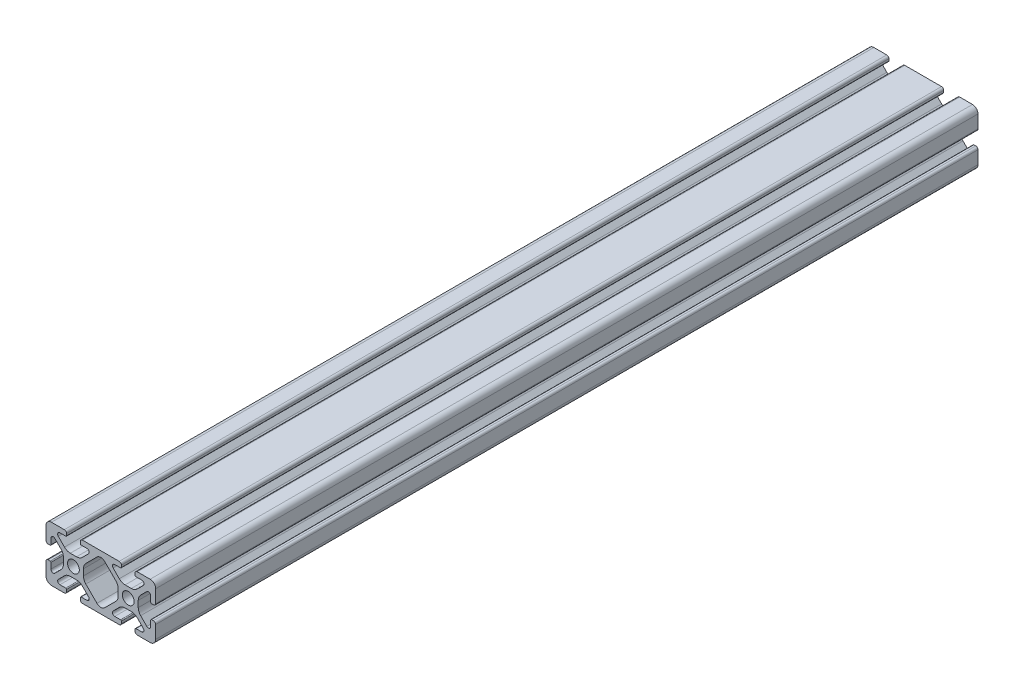
from build123d import *

# Parameters (mm, degrees)
SKIZZE1_R                       = 2.15
AUFSATZ_LINEAR_AUSTRAGEN1_DEPTH = 300


with BuildPart() as part:
    # Skizze1 → Aufsatz-Linear austragen1 (new body)
    with BuildSketch(Plane.XY.offset(20)):
        with BuildLine():
            Line((32.499999987, 1.499999997), (32.499999987, 0.800000002))
            ThreePointArc((32.499999987, 0.800000002), (32.734314563, 0.234314576), (33.29999999, 0))
            Line((33.29999999, 0), (38, 0))
            ThreePointArc((38, 0), (39.414213562, 0.585786438), (40, 2))
            Line((40, 2), (40, 6.700000003))
            ThreePointArc((40, 6.700000003), (39.765685425, 7.265685427), (39.2, 7.500000003))
            Line((39.2, 7.500000003), (38.499999994, 7.500000003))
            ThreePointArc((38.499999994, 7.500000003), (38.28786796, 7.412132037), (38.199999994, 7.200000003))
            Line((38.199999994, 7.200000003), (38.199999994, 5.082411608))
            ThreePointArc((38.199999994, 5.082411608), (37.686138516, 4.313363559), (36.77898449, 4.493807714))
            Line((36.77898449, 4.493807714), (34.52867965, 6.744112554))
            ThreePointArc((34.52867965, 6.744112554), (33.878361397, 7.717382599), (33.649999994, 8.865432896))
            Line((33.649999994, 8.865432896), (33.649999994, 11.134567107))
            ThreePointArc((33.649999994, 11.134567107), (33.878361397, 12.282617403), (34.52867965, 13.255887448))
            Line((34.52867965, 13.255887448), (36.778984494, 15.506192293))
            ThreePointArc((36.778984494, 15.506192293), (37.686138518, 15.686636447), (38.199999994, 14.9175884))
            Line((38.199999994, 14.9175884), (38.199999994, 12.800000003))
            ThreePointArc((38.199999994, 12.800000003), (38.287867961, 12.587867967), (38.499999997, 12.5))
            Line((38.499999997, 12.5), (39.199999998, 12.5))
            ThreePointArc((39.199999998, 12.5), (39.765685424, 12.734314576), (40, 13.300000002))
            Line((40, 13.300000002), (40, 18))
            ThreePointArc((40, 18), (39.414213562, 19.414213562), (38, 20))
            Line((38, 20), (33.299999987, 20))
            ThreePointArc((33.299999987, 20), (32.734314562, 19.765685425), (32.499999987, 19.2))
            Line((32.499999987, 19.2), (32.499999987, 18.499999997))
            ThreePointArc((32.499999987, 18.499999997), (32.587867953, 18.287867963), (32.799999987, 18.199999997))
            Line((32.799999987, 18.199999997), (34.917587987, 18.199999997))
            ThreePointArc((34.917587987, 18.199999997), (35.686635928, 17.686138591), (35.506191799, 16.778984692))
            Line((35.506191799, 16.778984692), (33.255886765, 14.528679659))
            ThreePointArc((33.255886765, 14.528679659), (32.28261672, 13.878361405), (31.134566423, 13.650000003))
            Line((31.134566423, 13.650000003), (28.865432887, 13.650000003))
            ThreePointArc((28.865432887, 13.650000003), (27.717382591, 13.878361405), (26.744112545, 14.528679659))
            Line((26.744112545, 14.528679659), (24.493807705, 16.778984499))
            ThreePointArc((24.493807705, 16.778984499), (24.313363551, 17.686138521), (25.082411597, 18.199999997))
            Line((25.082411597, 18.199999997), (27.199999997, 18.199999997))
            ThreePointArc((27.199999997, 18.199999997), (27.412132033, 18.287867964), (27.5, 18.5))
            Line((27.5, 18.5), (27.5, 19.199999998))
            ThreePointArc((27.5, 19.199999998), (27.265685424, 19.765685424), (26.699999998, 20))
            Line((26.699999998, 20), (13.299999987, 20))
            ThreePointArc((13.299999987, 20), (12.734314562, 19.765685425), (12.499999987, 19.2))
            Line((12.499999987, 19.2), (12.499999987, 18.499999997))
            ThreePointArc((12.499999987, 18.499999997), (12.587867953, 18.287867963), (12.799999987, 18.199999997))
            Line((12.799999987, 18.199999997), (14.917588393, 18.199999997))
            ThreePointArc((14.917588393, 18.199999997), (15.686636443, 17.686138519), (15.506192288, 16.778984492))
            Line((15.506192288, 16.778984492), (13.255887455, 14.528679659))
            ThreePointArc((13.255887455, 14.528679659), (12.282617409, 13.878361405), (11.134567113, 13.650000003))
            Line((11.134567113, 13.650000003), (8.865432887, 13.650000003))
            ThreePointArc((8.865432887, 13.650000003), (7.717382591, 13.878361405), (6.744112545, 14.528679659))
            Line((6.744112545, 14.528679659), (4.493807705, 16.778984499))
            ThreePointArc((4.493807705, 16.778984499), (4.313363551, 17.686138521), (5.082411597, 18.199999997))
            Line((5.082411597, 18.199999997), (7.199999997, 18.199999997))
            ThreePointArc((7.199999997, 18.199999997), (7.412132033, 18.287867964), (7.5, 18.5))
            Line((7.5, 18.5), (7.5, 19.199999998))
            ThreePointArc((7.5, 19.199999998), (7.265685424, 19.765685424), (6.699999997, 20))
            Line((6.699999997, 20), (2, 20))
            ThreePointArc((2, 20), (0.585786438, 19.414213562), (0, 18))
            Line((0, 18), (0, 13.3))
            ThreePointArc((0, 13.3), (0.234314575, 12.734314575), (0.8, 12.5))
            Line((0.8, 12.5), (1.500000005, 12.5))
            ThreePointArc((1.500000005, 12.5), (1.71213204, 12.587867966), (1.800000005, 12.8))
            Line((1.800000005, 12.8), (1.800000005, 14.91758839))
            ThreePointArc((1.800000005, 14.91758839), (2.313861483, 15.686636439), (3.22101551, 15.506192284))
            Line((3.22101551, 15.506192284), (5.471320344, 13.25588745))
            ThreePointArc((5.471320344, 13.25588745), (6.121638597, 12.282617404), (6.35, 11.134567108))
            Line((6.35, 11.134567108), (6.35, 8.86543289))
            ThreePointArc((6.35, 8.86543289), (6.121638597, 7.717382593), (5.471320344, 6.744112548))
            Line((5.471320344, 6.744112548), (3.221015504, 4.493807708))
            ThreePointArc((3.221015504, 4.493807708), (2.313861481, 4.313363554), (1.800000005, 5.0824116))
            Line((1.800000005, 5.0824116), (1.800000005, 7.2))
            ThreePointArc((1.800000005, 7.2), (1.712132039, 7.412132036), (1.500000003, 7.500000003))
            Line((1.500000003, 7.500000003), (0.800000003, 7.500000002))
            ThreePointArc((0.800000003, 7.500000002), (0.234314576, 7.265685427), (0, 6.7))
            Line((0, 6.7), (0, 2))
            ThreePointArc((0, 2), (0.585786438, 0.585786438), (2, 0))
            Line((2, 0), (6.7, 0))
            ThreePointArc((6.7, 0), (7.265685425, 0.234314575), (7.5, 0.8))
            Line((7.5, 0.8), (7.5, 1.5))
            ThreePointArc((7.5, 1.5), (7.412132034, 1.712132034), (7.2, 1.8))
            Line((7.2, 1.8), (5.0824116, 1.8))
            ThreePointArc((5.0824116, 1.8), (4.313363551, 2.313861478), (4.493807706, 3.221015504))
            Line((4.493807706, 3.221015504), (6.744112546, 5.471320344))
            ThreePointArc((6.744112546, 5.471320344), (7.717382592, 6.121638598), (8.865432888, 6.35))
            Line((8.865432888, 6.35), (11.134567107, 6.35))
            ThreePointArc((11.134567107, 6.35), (12.282617403, 6.121638598), (13.255887449, 5.471320344))
            Line((13.255887449, 5.471320344), (15.506192293, 3.2210155))
            ThreePointArc((15.506192293, 3.2210155), (15.686636447, 2.313861477), (14.9175884, 1.8))
            Line((14.9175884, 1.8), (12.79999999, 1.8))
            ThreePointArc((12.79999999, 1.8), (12.587867954, 1.712132033), (12.499999987, 1.499999997))
            Line((12.499999987, 1.499999997), (12.499999987, 0.800000002))
            ThreePointArc((12.499999987, 0.800000002), (12.734314563, 0.234314576), (13.29999999, 0))
            Line((13.29999999, 0), (26.7, 0))
            ThreePointArc((26.7, 0), (27.265685425, 0.234314575), (27.5, 0.8))
            Line((27.5, 0.8), (27.5, 1.5))
            ThreePointArc((27.5, 1.5), (27.412132034, 1.712132034), (27.2, 1.8))
            Line((27.2, 1.8), (25.0824116, 1.8))
            ThreePointArc((25.0824116, 1.8), (24.313363551, 2.313861478), (24.493807706, 3.221015504))
            Line((24.493807706, 3.221015504), (26.744112546, 5.471320344))
            ThreePointArc((26.744112546, 5.471320344), (27.717382592, 6.121638598), (28.865432888, 6.35))
            Line((28.865432888, 6.35), (31.134567114, 6.35))
            ThreePointArc((31.134567114, 6.35), (32.28261741, 6.121638598), (33.255887456, 5.471320344))
            Line((33.255887456, 5.471320344), (35.50619239, 3.22101541))
            ThreePointArc((35.50619239, 3.22101541), (35.686636533, 2.313861444), (34.917588535, 1.8))
            Line((34.917588535, 1.8), (32.79999999, 1.8))
            ThreePointArc((32.79999999, 1.8), (32.587867954, 1.712132033), (32.499999987, 1.499999997))
        make_face()
        with Locations((10, 10)):
            Circle(SKIZZE1_R, mode=Mode.SUBTRACT)
        with Locations((30, 10)):
            Circle(SKIZZE1_R, mode=Mode.SUBTRACT)
        with BuildLine():
            Line((18.585786095, 2.687006109), (14.528679095, 6.744113109))
            ThreePointArc((14.528679095, 6.744113109), (13.878360842, 7.717383154), (13.64999944, 8.86543345))
            Line((13.64999944, 8.86543345), (13.64999944, 11.134566552))
            ThreePointArc((13.64999944, 11.134566552), (13.878360842, 12.282616848), (14.528679095, 13.255886894))
            Line((14.528679095, 13.255886894), (18.585786441, 17.312994239))
            ThreePointArc((18.585786441, 17.312994239), (20.000000001, 17.898780676), (21.414213561, 17.312994239))
            Line((21.414213561, 17.312994239), (25.471320215, 13.255887585))
            ThreePointArc((25.471320215, 13.255887585), (26.121638469, 12.282617539), (26.349999871, 11.134567243))
            Line((26.349999871, 11.134567243), (26.349999871, 8.86543345))
            ThreePointArc((26.349999871, 8.86543345), (26.121638469, 7.717383154), (25.471320215, 6.744113109))
            Line((25.471320215, 6.744113109), (21.414213215, 2.687006109))
            ThreePointArc((21.414213215, 2.687006109), (19.999999655, 2.101219672), (18.585786095, 2.687006109))
        make_face(mode=Mode.SUBTRACT)
    extrude(amount=-AUFSATZ_LINEAR_AUSTRAGEN1_DEPTH)


solid = part.part
